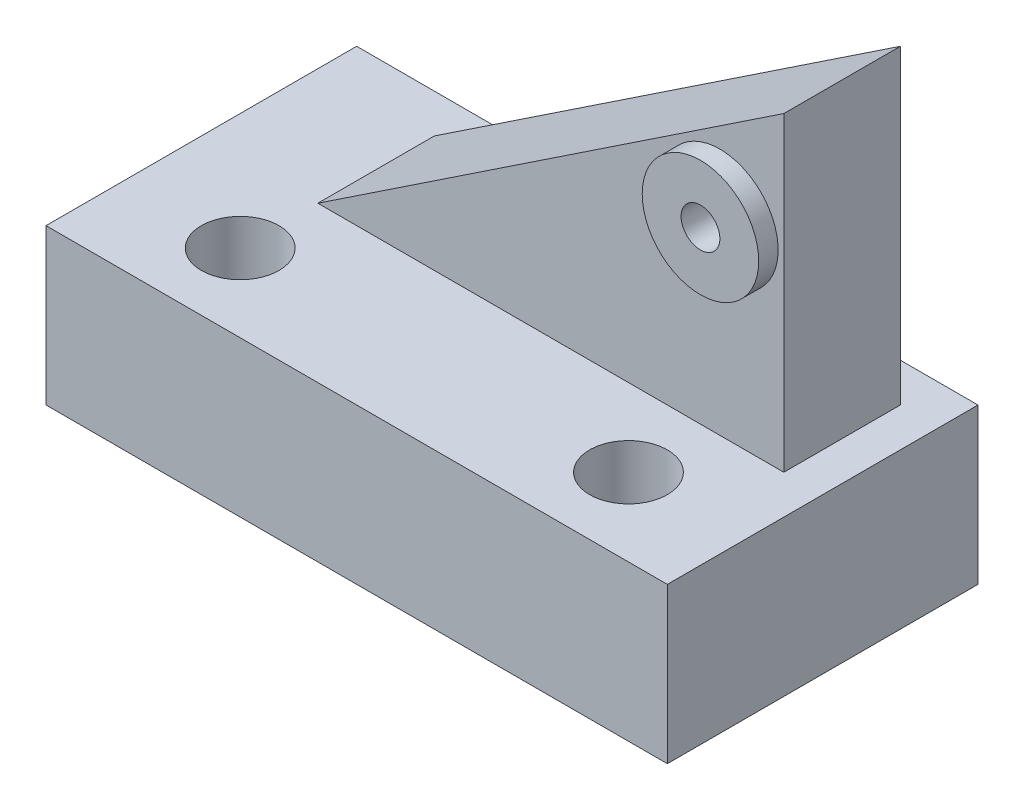
from build123d import *

# Parameters (mm, degrees)
SKETCH1_W           = 101.6
SKETCH1_H           = 50.8
BOSS_EXTRUDE1_DEPTH = 25.4
SKETCH2_W           = 76.2
SKETCH2_H           = 19.05
BOSS_EXTRUDE2_DEPTH = 50.8
CUT_EXTRUDE1_DEPTH  = 26.4
SKETCH4_R           = 3.175
CUT_EXTRUDE3_DEPTH  = 26.4
SKETCH4_3_R         = 9.525
SKETCH4_3_R_2       = 3.175
BOSS_EXTRUDE3_DEPTH = 3.175
SKETCH5_R           = 6.35
CUT_EXTRUDE4_DEPTH  = 26.4


with BuildPart() as part:
    # Sketch1 → Boss-Extrude1 (new body)
    with BuildSketch(Plane(origin=(0, 0, 0), x_dir=(1, 0, 0), z_dir=(0, 1, 0))):
        with Locations((50.8, 25.4)):
            Rectangle(SKETCH1_W, SKETCH1_H)
    extrude(amount=BOSS_EXTRUDE1_DEPTH)

    # Sketch2 → Boss-Extrude2 (add)
    with BuildSketch(Plane(origin=(0, 25.4, 0), x_dir=(1, 0, 0), z_dir=(0, 1, 0))):
        with Locations((57.15, 34.925)):
            Rectangle(SKETCH2_W, SKETCH2_H)
    extrude(amount=BOSS_EXTRUDE2_DEPTH)

    # Sketch3 → Cut-Extrude1 (cut, through all)
    with BuildSketch(Plane.XY.offset(-25.4)):
        Polygon((19.05, 76.2), (95.25, 76.2), (19.05, 25.4), align=None)
    extrude(amount=-CUT_EXTRUDE1_DEPTH, mode=Mode.SUBTRACT)

    # Sketch4 → Cut-Extrude3 (cut, through all)
    with BuildSketch(Plane.XY.offset(-25.4)):
        with Locations((84.791572172, 56.416317707)):
            Circle(SKETCH4_R)
    extrude(amount=-CUT_EXTRUDE3_DEPTH, mode=Mode.SUBTRACT)

    # Sketch4_3 → Boss-Extrude3 (add)
    with BuildSketch(Plane.XY.offset(-25.4)):
        with Locations(Location((84.791572172, 56.416317707, 0), (0, 0, 180))):  # turned: the seam where the file's is
            Circle(SKETCH4_3_R)
        with Locations((84.791572172, 56.416317707)):
            Circle(SKETCH4_3_R_2, mode=Mode.SUBTRACT)
    extrude(amount=BOSS_EXTRUDE3_DEPTH)

    # Sketch5 → Cut-Extrude4 (cut, through all)
    with BuildSketch(Plane(origin=(0, 25.4, 0), x_dir=(1, 0, 0), z_dir=(0, 1, 0))):
        with Locations(Location((19.05, 12.7, 0), (0, 0, 270))):  # turned: the seam where the file's is
            Circle(SKETCH5_R)
        with Locations(Location((82.55, 12.7, 0), (0, 0, 270))):  # turned: the seam where the file's is
            Circle(SKETCH5_R)
    extrude(amount=-CUT_EXTRUDE4_DEPTH, mode=Mode.SUBTRACT)


solid = part.part
